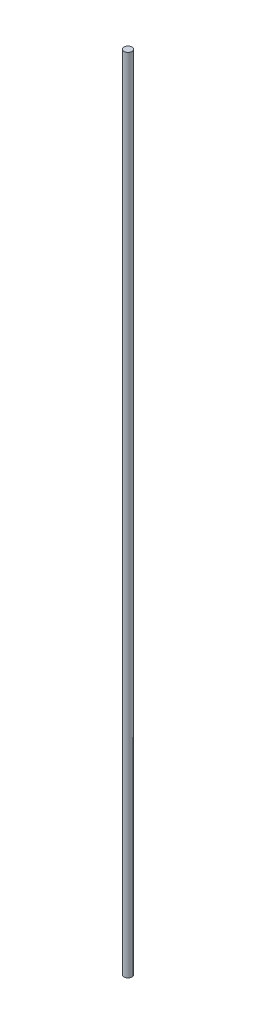
from build123d import *

# Parameters (mm, degrees)
CROQUIS1_R              = 2.1
SALIENTE_EXTRUIR1_DEPTH = 429


with BuildPart() as part:
    # Croquis1 → Saliente-Extruir1 (new body)
    with BuildSketch(Plane(origin=(0, 0, 0), x_dir=(1, 0, 0), z_dir=(0, 1, 0))):
        Circle(CROQUIS1_R)
    extrude(amount=SALIENTE_EXTRUIR1_DEPTH)


solid = part.part
